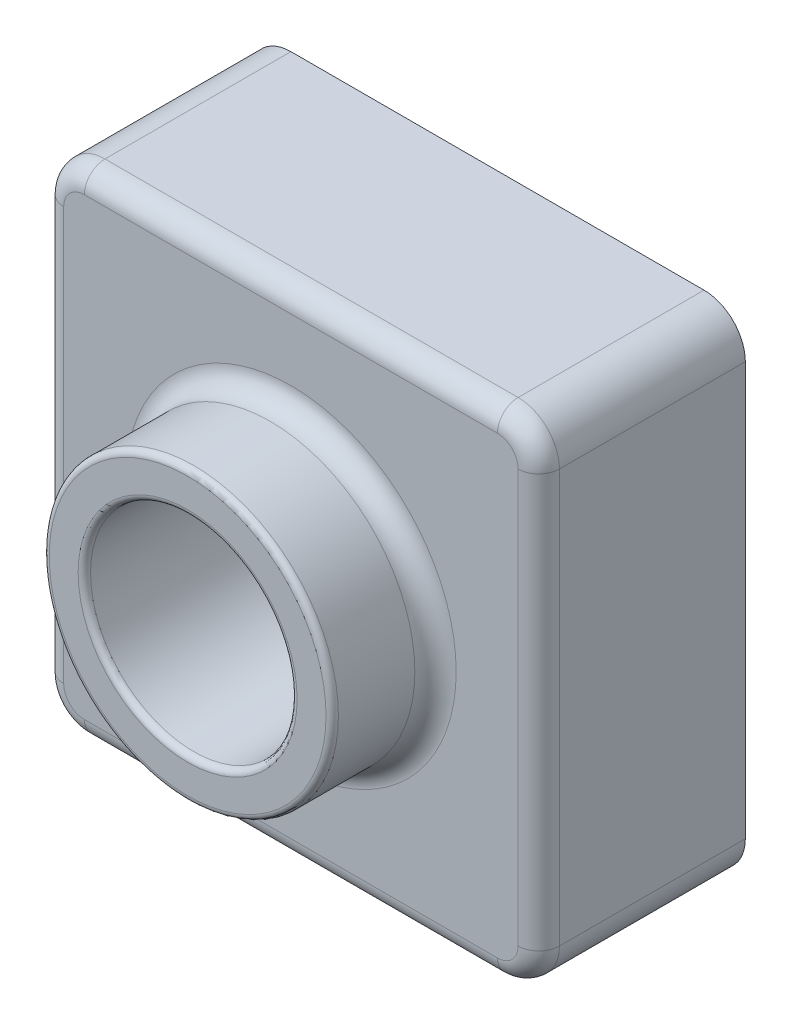
from build123d import *

# Parameters (mm, degrees)
SKETCH1_W           = 120
SKETCH1_H           = 120
BOSS_EXTRUDE2_DEPTH = 50
SKETCH2_R           = 35
BOSS_EXTRUDE3_DEPTH = 25
SKETCH3_R           = 25
CUT_EXTRUDE1_DEPTH  = 55
FILLET1_R           = 10
FILLET2_R           = 1.5
FILLET3_R           = 5
SHELL1_T            = -2


with BuildPart() as part:
    # Sketch1 → Boss-Extrude2 (new body)
    with BuildSketch(Plane.XY):
        Rectangle(SKETCH1_W, SKETCH1_H)
    extrude(amount=BOSS_EXTRUDE2_DEPTH)

    # Sketch2 → Boss-Extrude3 (add)
    with BuildSketch(Plane.XY.offset(50)):
        Circle(SKETCH2_R)
    extrude(amount=BOSS_EXTRUDE3_DEPTH)

    # Sketch3 → Cut-Extrude1 (cut)
    with BuildSketch(Plane.XY.offset(75)):
        Circle(SKETCH3_R)
    extrude(amount=-CUT_EXTRUDE1_DEPTH, mode=Mode.SUBTRACT)

    # Fillet1
    fillet1_edges = [part.edges().sort_by_distance(p)[0] for p in [
        (-60, 60, 25),
        (-60, -60, 25),
        (60, -60, 25),
        (60, 60, 25),
    ]]
    fillet(fillet1_edges, radius=FILLET1_R)

    # Fillet2
    fillet2_edges = [part.edges().sort_by_distance(p)[0] for p in [
        (-35, 0, 75),
        (-25, 0, 75),
    ]]
    fillet(fillet2_edges, radius=FILLET2_R)

    # Fillet3
    fillet3_edges = [part.edges().sort_by_distance(p)[0] for p in [
        (-35, 0, 50),
        (-60, 0, 50),
        (0, 60, 50),
        (0, -60, 50),
        (60, 0, 50),
        (-57.071067812, -57.071067812, 50),
        (57.071067812, -57.071067812, 50),
        (57.071067812, 57.071067812, 50),
        (-57.071067812, 57.071067812, 50),
    ]]
    fillet(fillet3_edges, radius=FILLET3_R)

    # Shell1
    shell1_openings = [part.faces().sort_by_distance(p)[0] for p in [
        (0, 0, 0),
    ]]
    offset(amount=SHELL1_T, openings=shell1_openings, kind=Kind.INTERSECTION)


solid = part.part
